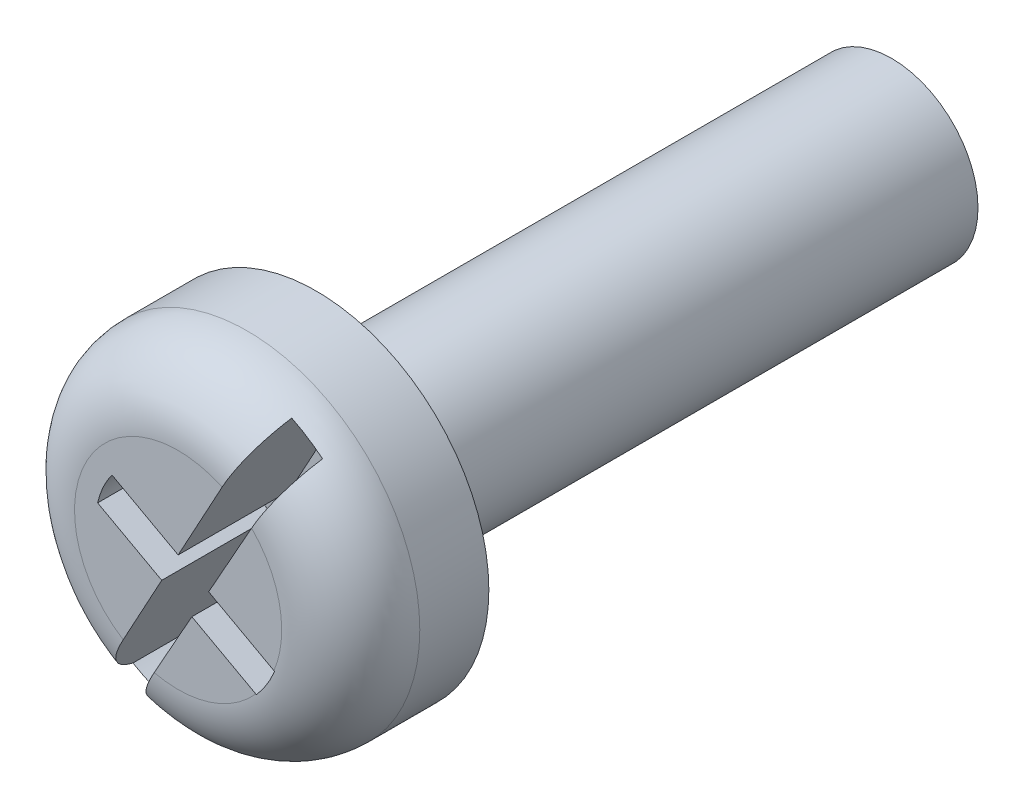
from build123d import *

# Parameters (mm, degrees)
SZKIC1_R                    = 3
DODANIE_WYCI_GNI_CIE2_DEPTH = 2.4
SZKIC2_R                    = 1.5
DODANIE_WYCI_GNI_CIE3_DEPTH = 10
ZAOKR_GLENIE2_R             = 1.2
WYTNIJ_WYCI_GNI_CIE1_DEPTH  = 1.94


with BuildPart() as part:
    # Szkic1 → Dodanie-wyciągnięcie2 (new body)
    with BuildSketch(Plane.XY):
        with Locations((-1.860516246, 2.732142857)):
            Circle(SZKIC1_R)
    extrude(amount=DODANIE_WYCI_GNI_CIE2_DEPTH)

    # Szkic2 → Dodanie-wyciągnięcie3 (add)
    with BuildSketch(Plane(origin=(0, 0, 0), x_dir=(-1, 0, 0), z_dir=(0, 0, -1))):
        with Locations((1.860516246, 2.732142857)):
            Circle(SZKIC2_R)
    extrude(amount=DODANIE_WYCI_GNI_CIE3_DEPTH)

    # Zaokrąglenie2
    zaokr_glenie2_edges = [part.edges().sort_by_distance(p)[0] for p in [
        (-4.860516246, 2.732142857, 2.4),
    ]]
    fillet(zaokr_glenie2_edges, radius=ZAOKR_GLENIE2_R)

    # Szkic3 → Wytnij-wyciągnięcie1 (cut)
    with BuildSketch(Plane.XY.offset(2.4)):
        with BuildLine():
            Line((-1.859548318, 2.959091853), (-0.575649693, 5.316481314))
            ThreePointArc((-0.575649693, 5.316481314), (-0.297886623, 5.158637444), (-0.039271083, 4.97106076))
            Line((-0.039271083, 4.97106076), (-1.329373025, 2.669425378))
            Line((-1.329373025, 2.669425378), (-0.183967515, 2.043621837))
            ThreePointArc((-0.183967515, 2.043621837), (-0.320475658, 1.776553075), (-0.499159616, 1.535654258))
            Line((-0.499159616, 1.535654258), (-1.621312108, 2.148584891))
            Line((-1.621312108, 2.148584891), (-2.819933608, 0.01015725))
            ThreePointArc((-2.819933608, 0.01015725), (-3.083174674, 0.117799023), (-3.33454353, 0.250826496))
            Line((-3.33454353, 0.250826496), (-2.145142944, 2.434706401))
            Line((-2.145142944, 2.434706401), (-3.258687897, 3.042935511))
            ThreePointArc((-3.258687897, 3.042935511), (-3.162842423, 3.328316127), (-3.009463836, 3.587359481))
            Line((-3.009463836, 3.587359481), (-1.859548318, 2.959091853))
        make_face()
    extrude(amount=-WYTNIJ_WYCI_GNI_CIE1_DEPTH, mode=Mode.SUBTRACT)


solid = part.part
